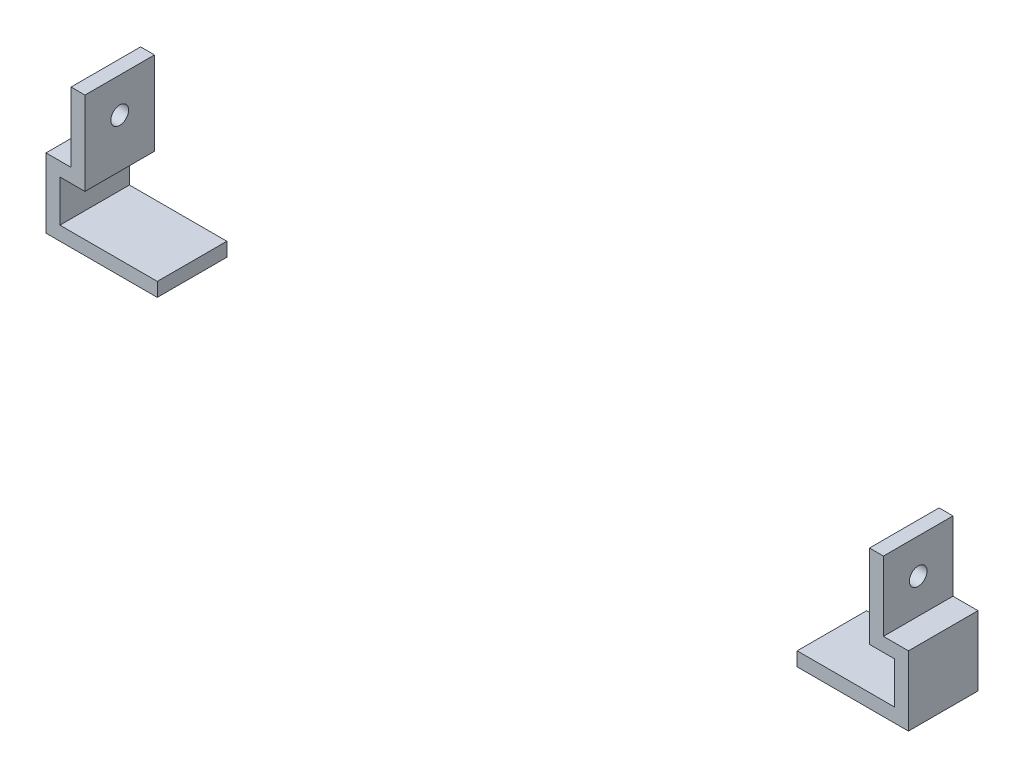
from build123d import *

# Parameters (mm, degrees)
SKETCH1_W           = 4
SKETCH1_H           = 5
SKETCH1_W_2         = 5
SKETCH1_H_2         = 25
BOSS_EXTRUDE1_DEPTH = 25
SKETCH2_R           = 3.175
CUT_EXTRUDE1_DEPTH  = 302


with BuildPart() as part:
    # Sketch1 → Boss-Extrude1 (new body)
    with BuildSketch(Plane.XY):
        Polygon((-115, -35), (-115, -30), (-150, -30), (-155, -30), (-155, -35), align=None)
        Polygon((-150, -10), (-155, -10), (-155, -30), (-150, -30), (-150, -15), align=None)
        with Locations((-148, -12.5)):
            Rectangle(SKETCH1_W, SKETCH1_H)
        with Locations((-143.5, -12.5)):
            Rectangle(SKETCH1_W_2, SKETCH1_H)
        with Locations((-143.5, 2.5)):
            Rectangle(SKETCH1_W_2, SKETCH1_H_2)
        Polygon((150, -30), (115, -30), (115, -35), (155, -35), (155, -30), align=None)
        Polygon((155, -10), (155, -30), (150, -30), (150, -15), (150, -10), align=None)
        with Locations((148, -12.5)):
            Rectangle(SKETCH1_W, SKETCH1_H)
        with Locations((143.5, -12.5)):
            Rectangle(SKETCH1_W_2, SKETCH1_H)
        with Locations((143.5, 2.5)):
            Rectangle(SKETCH1_W_2, SKETCH1_H_2)
    extrude(amount=BOSS_EXTRUDE1_DEPTH)

    # Sketch2 → Cut-Extrude1 (cut, through all)
    with BuildSketch(Plane(origin=(146, 0, 0), x_dir=(0, 0, -1), z_dir=(1, 0, 0))):
        with Locations((-12.5, 2.5)):
            Circle(SKETCH2_R)
    extrude(amount=-CUT_EXTRUDE1_DEPTH, mode=Mode.SUBTRACT)


solid = part.part
